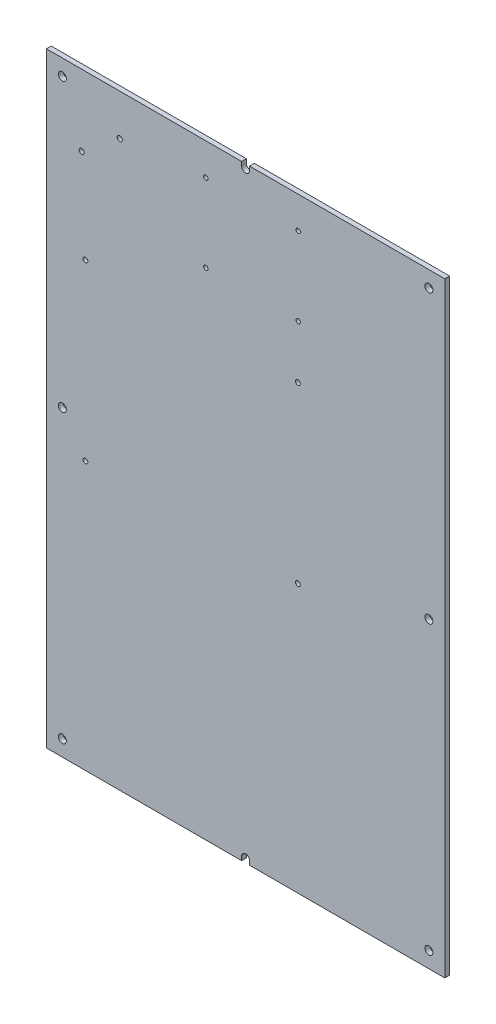
from build123d import *

# Parameters (mm, degrees)
ESQUISSE1_R        = 1.375
ESQUISSE1_R_2      = 1.5
ESQUISSE1_R_3      = 2.5
ESQUISSE1_R_4      = 1.6
BOSS_EXTRU_1_DEPTH = 3


with BuildPart() as part:
    # Esquisse1 → Boss.-Extru.1 (new body)
    with BuildSketch(Plane.XY):
        with BuildLine():
            Line((92.337784558, -311.352829028), (92.337784558, -313.852829028))
            Line((92.337784558, -313.852829028), (214.837784558, -313.852829028))
            Line((214.837784558, -313.852829028), (214.837784558, 66.147170972))
            Line((214.837784558, 66.147170972), (92.337784558, 66.147170972))
            Line((92.337784558, 66.147170972), (92.337784558, 63.647170972))
            ThreePointArc((92.337784558, 63.647170972), (89.837784558, 61.147170972), (87.337784558, 63.647170972))
            Line((87.337784558, 63.647170972), (87.337784558, 66.147170972))
            Line((87.337784558, 66.147170972), (-35.162215442, 66.147170972))
            Line((-35.162215442, 66.147170972), (-35.162215442, -313.852829028))
            Line((-35.162215442, -313.852829028), (87.337784558, -313.852829028))
            Line((87.337784558, -313.852829028), (87.337784558, -311.352829028))
            ThreePointArc((87.337784558, -311.352829028), (89.837784558, -308.852829028), (92.337784558, -311.352829028))
        make_face()
        with Locations((64.837784558, 46.147170972)):
            Circle(ESQUISSE1_R, mode=Mode.SUBTRACT)
        with Locations((122.837784558, 46.147170972)):
            Circle(ESQUISSE1_R, mode=Mode.SUBTRACT)
        with Locations((64.837784558, -2.852829028)):
            Circle(ESQUISSE1_R, mode=Mode.SUBTRACT)
        with Locations((122.837784558, -2.852829028)):
            Circle(ESQUISSE1_R, mode=Mode.SUBTRACT)
        with Locations((-10.69098659, -36.352829028)):
            Circle(ESQUISSE1_R_2, mode=Mode.SUBTRACT)
        with Locations((122.65901341, -36.352829028)):
            Circle(ESQUISSE1_R_2, mode=Mode.SUBTRACT)
        with Locations((122.65901341, -145.572829028)):
            Circle(ESQUISSE1_R_2, mode=Mode.SUBTRACT)
        with Locations((-10.69098659, -145.572829028)):
            Circle(ESQUISSE1_R_2, mode=Mode.SUBTRACT)
        with Locations((-25.162215442, 56.147170972)):
            Circle(ESQUISSE1_R_3, mode=Mode.SUBTRACT)
        with Locations((204.837784558, 56.147170972)):
            Circle(ESQUISSE1_R_3, mode=Mode.SUBTRACT)
        with Locations((204.837784558, -303.852829028)):
            Circle(ESQUISSE1_R_3, mode=Mode.SUBTRACT)
        with Locations((-25.162215442, -303.852829028)):
            Circle(ESQUISSE1_R_3, mode=Mode.SUBTRACT)
        with Locations((204.837784558, -123.852829028)):
            Circle(ESQUISSE1_R_3, mode=Mode.SUBTRACT)
        with Locations((-25.162215442, -123.852829028)):
            Circle(ESQUISSE1_R_3, mode=Mode.SUBTRACT)
        with Locations((10.84901341, 40.328880037)):
            Circle(ESQUISSE1_R_4, mode=Mode.SUBTRACT)
        with Locations((-13.02098659, 21.488880037)):
            Circle(ESQUISSE1_R_4, mode=Mode.SUBTRACT)
    extrude(amount=BOSS_EXTRU_1_DEPTH)


solid = part.part
